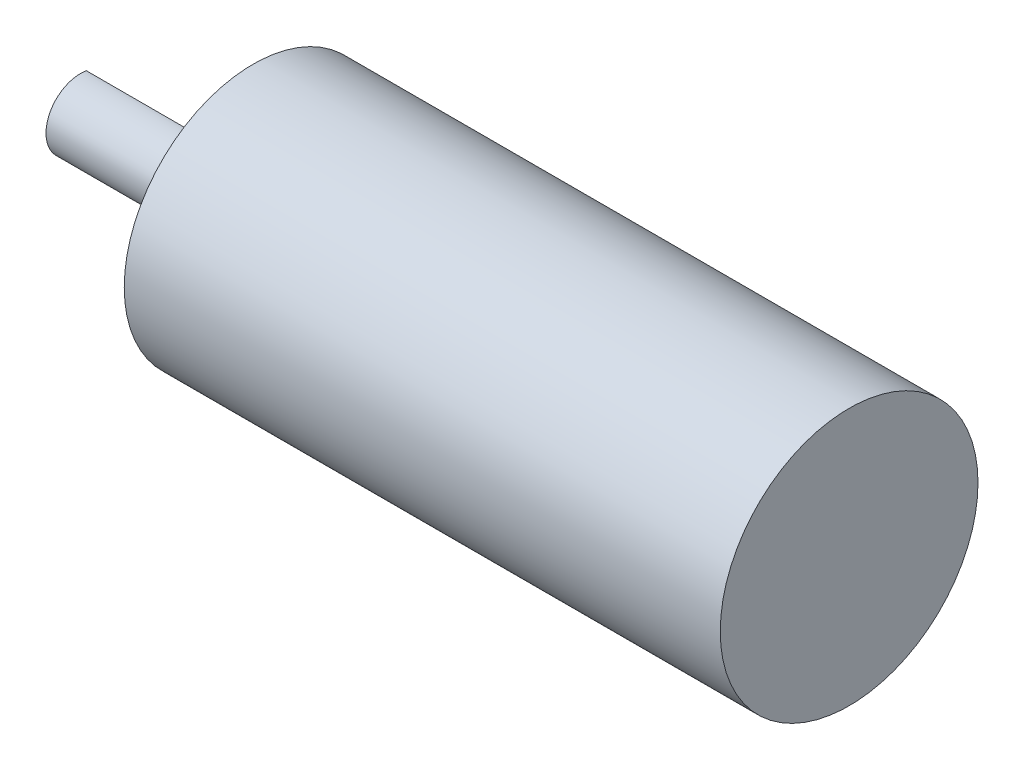
from build123d import *

# Parameters (mm, degrees)
SKETCH1_R           = 11.2
BOSS_EXTRUDE1_DEPTH = 51.8
BOSS_EXTRUDE2_DEPTH = 15


with BuildPart() as part:
    # Sketch1 → Boss-Extrude1 (new body)
    with BuildSketch(Plane(origin=(0, 0, 0), x_dir=(0, 0, -1), z_dir=(1, 0, 0))):
        Circle(SKETCH1_R)
    extrude(amount=-BOSS_EXTRUDE1_DEPTH)

    # Sketch2 → Boss-Extrude2 (add)
    with BuildSketch(Plane.ZY.offset(51.8)):
        with BuildLine():
            Line((-0.5, 2.958039892), (-0.5, -2.958039892))
            ThreePointArc((-0.5, -2.958039892), (3, 0), (-0.5, 2.958039892))
        make_face()
    extrude(amount=BOSS_EXTRUDE2_DEPTH)


solid = part.part
